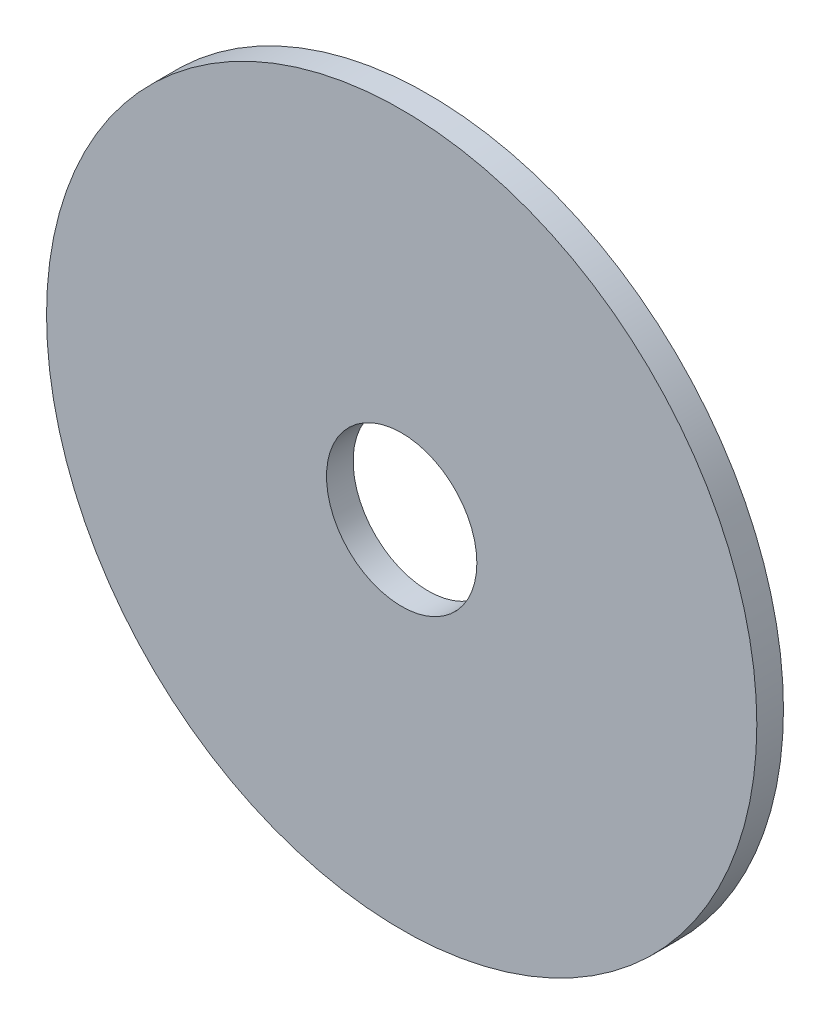
from build123d import *

# Parameters (mm, degrees)
SKETCH1_R           = 60
SKETCH1_R_2         = 12.7
BOSS_EXTRUDE1_DEPTH = 4.5


with BuildPart() as part:
    # Sketch1 → Boss-Extrude1 (new body)
    with BuildSketch(Plane.XY):
        Circle(SKETCH1_R)
        Circle(SKETCH1_R_2, mode=Mode.SUBTRACT)
    extrude(amount=BOSS_EXTRUDE1_DEPTH)


solid = part.part
